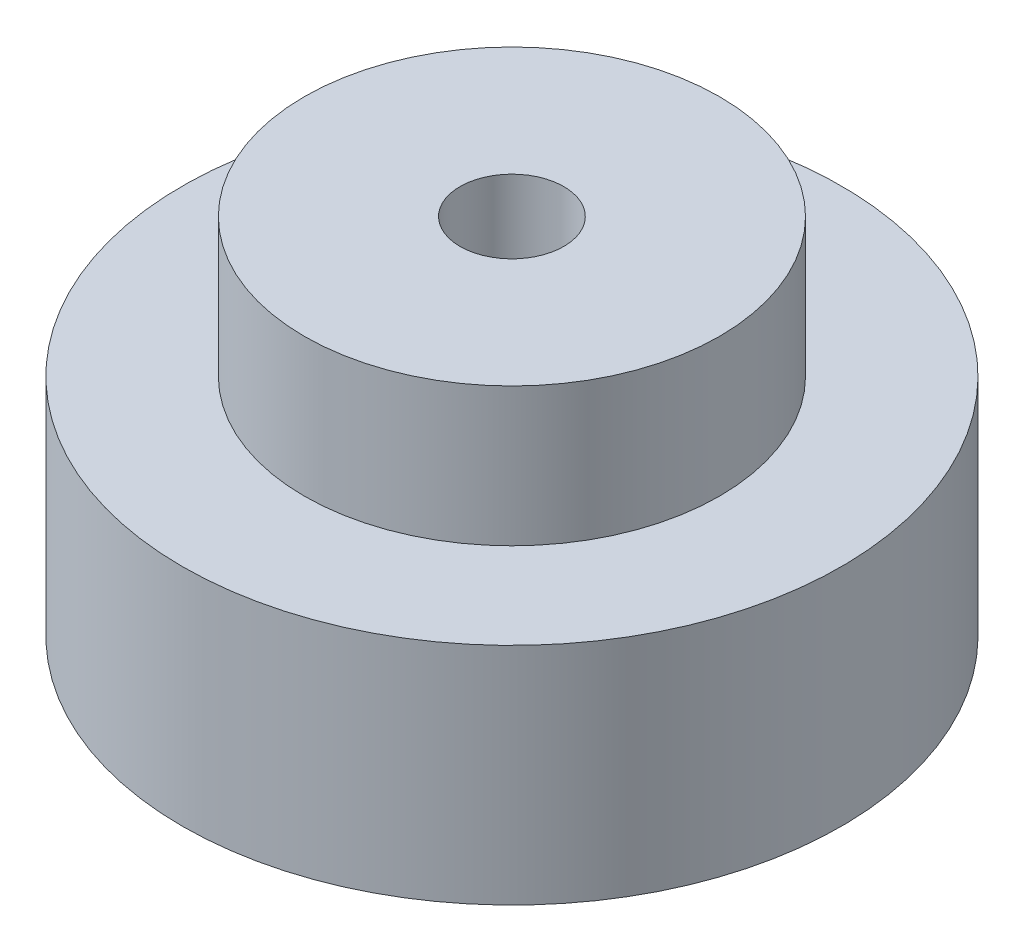
from build123d import *

# Parameters (mm, degrees)
SKETCH1_R           = 19.05
SKETCH1_R_2         = 3
BOSS_EXTRUDE1_DEPTH = 13
SKETCH2_R           = 12
SKETCH2_R_2         = 3
BOSS_EXTRUDE2_DEPTH = 8


with BuildPart() as part:
    # Sketch1 → Boss-Extrude1 (new body)
    with BuildSketch(Plane(origin=(0, 0, 0), x_dir=(1, 0, 0), z_dir=(0, 1, 0))):
        Circle(SKETCH1_R)
        Circle(SKETCH1_R_2, mode=Mode.SUBTRACT)
    extrude(amount=BOSS_EXTRUDE1_DEPTH)

    # Sketch2 → Boss-Extrude2 (add)
    with BuildSketch(Plane(origin=(0, 13, 0), x_dir=(1, 0, 0), z_dir=(0, 1, 0))):
        Circle(SKETCH2_R)
        Circle(SKETCH2_R_2, mode=Mode.SUBTRACT)
    extrude(amount=BOSS_EXTRUDE2_DEPTH)


solid = part.part
